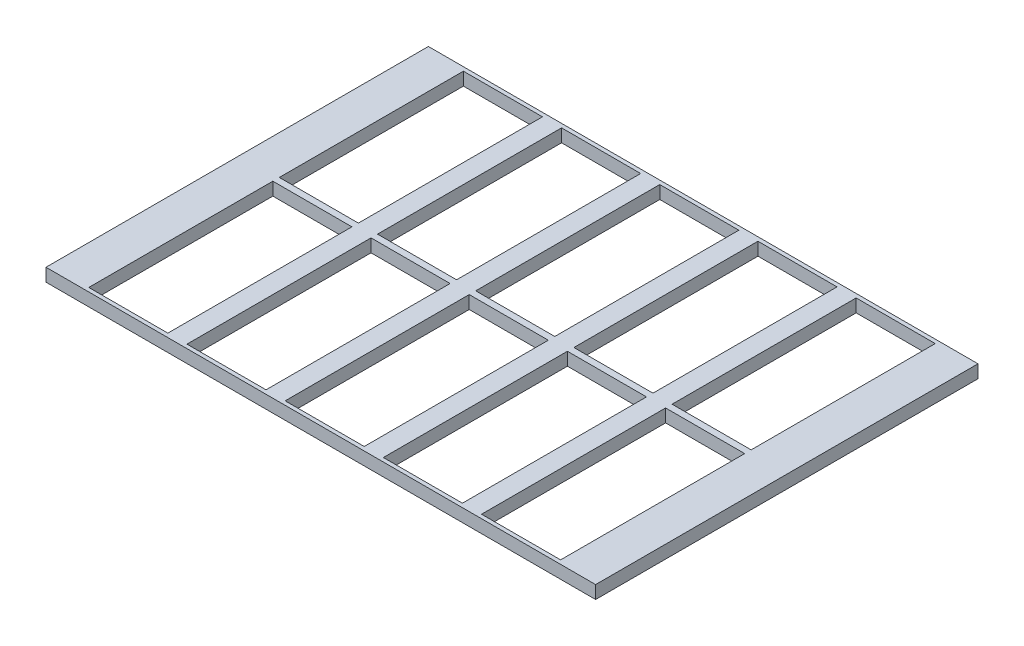
from build123d import *

# Parameters (mm, degrees)
SKETCH1_W           = 424
SKETCH1_H           = 295
SKETCH1_W_2         = 61
SKETCH1_H_2         = 142
BOSS_EXTRUDE1_DEPTH = 10


with BuildPart() as part:
    # Sketch1 → Boss-Extrude1 (new body)
    with BuildSketch(Plane(origin=(0, 0, 0), x_dir=(1, 0, 0), z_dir=(0, 1, 0))):
        Rectangle(SKETCH1_W, SKETCH1_H)
        with Locations((-151.5, 73.5)):
            Rectangle(SKETCH1_W_2, SKETCH1_H_2, mode=Mode.SUBTRACT)
        with Locations((-75.75, 73.5)):
            Rectangle(SKETCH1_W_2, SKETCH1_H_2, mode=Mode.SUBTRACT)
        with Locations((0, 73.5)):
            Rectangle(SKETCH1_W_2, SKETCH1_H_2, mode=Mode.SUBTRACT)
        with Locations((75.75, 73.5)):
            Rectangle(SKETCH1_W_2, SKETCH1_H_2, mode=Mode.SUBTRACT)
        with Locations((151.5, 73.5)):
            Rectangle(SKETCH1_W_2, SKETCH1_H_2, mode=Mode.SUBTRACT)
        with Locations((151.5, -73.5)):
            Rectangle(SKETCH1_W_2, SKETCH1_H_2, mode=Mode.SUBTRACT)
        with Locations((75.75, -73.5)):
            Rectangle(SKETCH1_W_2, SKETCH1_H_2, mode=Mode.SUBTRACT)
        with Locations((0, -73.5)):
            Rectangle(SKETCH1_W_2, SKETCH1_H_2, mode=Mode.SUBTRACT)
        with Locations((-75.75, -73.5)):
            Rectangle(SKETCH1_W_2, SKETCH1_H_2, mode=Mode.SUBTRACT)
        with Locations((-151.5, -73.5)):
            Rectangle(SKETCH1_W_2, SKETCH1_H_2, mode=Mode.SUBTRACT)
    extrude(amount=BOSS_EXTRUDE1_DEPTH)


solid = part.part
